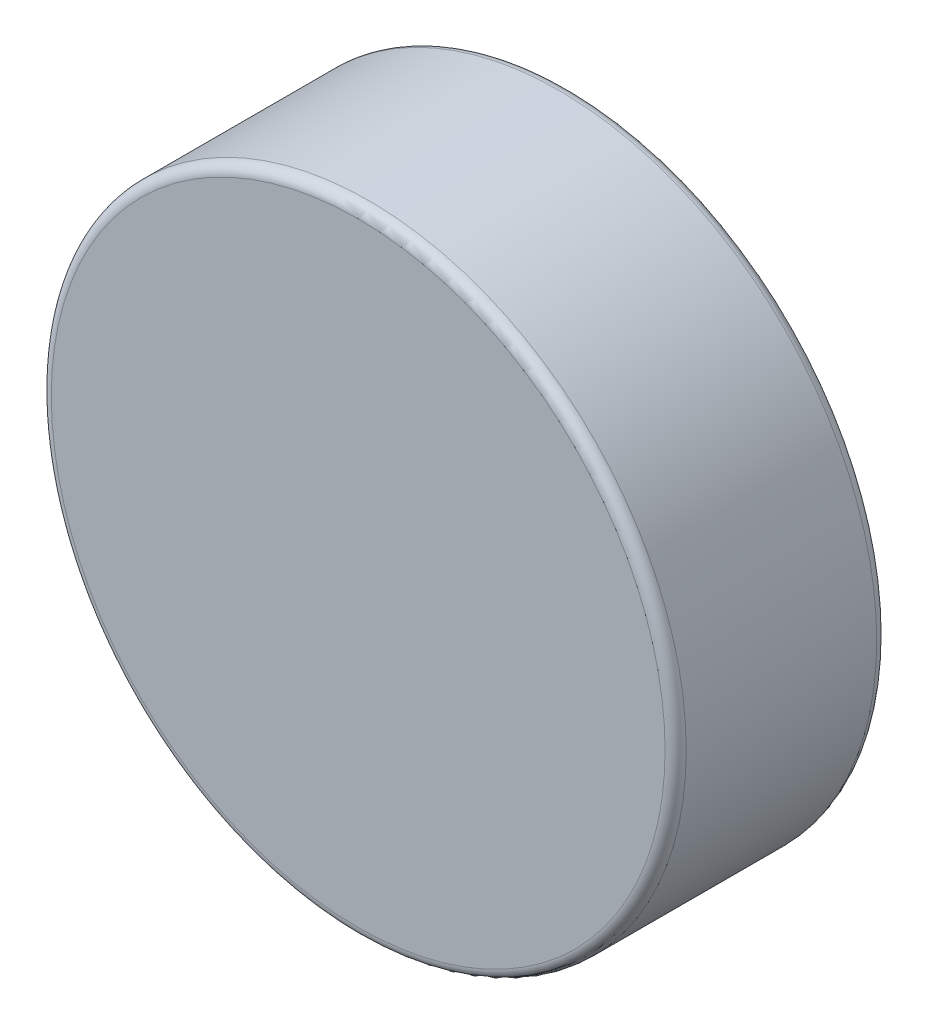
from build123d import *

# Parameters (mm, degrees)
SKETCH1_R           = 38.1
BOSS_EXTRUDE1_DEPTH = 25.4
FILLET1_R           = 1.27


with BuildPart() as part:
    # Sketch1 → Boss-Extrude1 (new body)
    with BuildSketch(Plane.XY):
        Circle(SKETCH1_R)
    extrude(amount=BOSS_EXTRUDE1_DEPTH)

    # Fillet1
    fillet1_edges = [part.edges().sort_by_distance(p)[0] for p in [
        (-38.1, 0, 0),
        (-38.1, 0, 25.4),
    ]]
    fillet(fillet1_edges, radius=FILLET1_R)


solid = part.part
